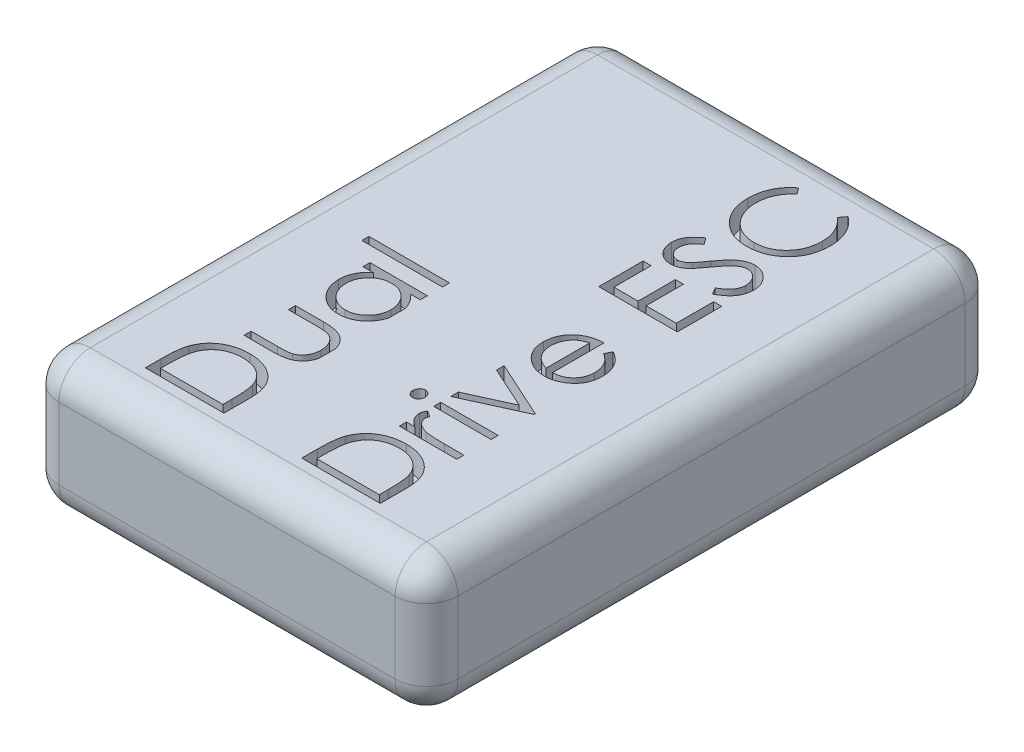
from build123d import *

# Parameters (mm, degrees)
SKETCH1_W           = 17.78
SKETCH1_H           = 25.4
BOSS_EXTRUDE1_DEPTH = 6
FILLET1_R           = 1.4
SKETCH2_W           = 3.58974359
SKETCH2_H           = 0.314102564
SKETCH2_W_2         = 2.557692308
CUT_EXTRUDE1_DEPTH  = 1


with BuildPart() as part:
    # Sketch1 → Boss-Extrude1 (new body)
    with BuildSketch(Plane(origin=(0, 0, 0), x_dir=(1, 0, 0), z_dir=(0, 1, 0))):
        with Locations((8.89, 12.7)):
            Rectangle(SKETCH1_W, SKETCH1_H)
    extrude(amount=BOSS_EXTRUDE1_DEPTH)

    # Fillet1
    fillet1_edges = [part.edges().sort_by_distance(p)[0] for p in [
        (17.78, 6, -12.7),
        (8.89, 6, -25.4),
        (0, 6, -12.7),
        (8.89, 0, -25.4),
        (17.78, 0, -12.7),
        (8.89, 0, 0),
        (0, 0, -12.7),
        (8.89, 6, 0),
        (0, 3, -25.4),
        (17.78, 3, -25.4),
        (17.78, 3, 0),
        (0, 3, 0),
    ]]
    fillet(fillet1_edges, radius=FILLET1_R)

    # Sketch2 → Cut-Extrude1 (cut)
    with BuildSketch(Plane(origin=(0, 6, 0), x_dir=(1, 0, 0), z_dir=(0, 1, 0))):
        with BuildLine():
            Line((3.403892312, 1.848717949), (6.903892312, 1.848717949))
            Line((6.903892312, 1.848717949), (6.903892312, 2.933353365))
            add(Edge.make_bspline(
                [(5.198062985, 4.720512821), (5.283343469, 4.720861509), (5.409315563, 4.713342182), (5.574129011, 4.691314552), (5.691735356, 4.666300928), (5.806063153, 4.635890145), (5.915896434, 4.596929309), (6.022236578, 4.552288757), (6.123667497, 4.500255599), (6.219702042, 4.443053958), (6.310299612, 4.382050173), (6.393449814, 4.315860667), (6.47133156, 4.246444464), (6.541864328, 4.172127597), (6.606333838, 4.093814865), (6.663660719, 4.011201923), (6.714745845, 3.923777373), (6.760429757, 3.830373639), (6.79853603, 3.728052702), (6.831538271, 3.617299225), (6.85779831, 3.497481653), (6.878949527, 3.369027162), (6.89845033, 3.180171866), (6.904427076, 3.033739775), (6.903892312, 2.933353365)],
                knots=[0, 0, 0, 0, 0.090812897, 0.134304288, 0.177036272, 0.218837427, 0.260261591, 0.301100084, 0.341636832, 0.381609041, 0.420147801, 0.457909661, 0.494760701, 0.531219285, 0.56696076, 0.602742115, 0.638232018, 0.674761113, 0.713377828, 0.754425315, 0.797801785, 0.843978981, 0.89306439, 1, 1, 1, 1], degree=3))
            add(Edge.make_bspline(
                [(3.530094235, 3.666025641), (3.558662483, 3.746791966), (3.611064859, 3.863508027), (3.698703507, 4.008186392), (3.772584338, 4.108669197), (3.854444017, 4.202214919), (3.943635575, 4.289907461), (4.042157086, 4.369578842), (4.148250416, 4.44247163), (4.260557449, 4.508211372), (4.37889391, 4.565350034), (4.502650765, 4.612801862), (4.631485957, 4.652204475), (4.765682526, 4.683214339), (4.954662157, 4.712058017), (5.09987701, 4.721034475), (5.198062985, 4.720512821)],
                knots=[0, 0, 0, 0, 0.121697081, 0.181159, 0.240076822, 0.298685898, 0.357632728, 0.417591519, 0.47848211, 0.540396536, 0.602335896, 0.664996664, 0.728553099, 0.793645821, 0.860531077, 1, 1, 1, 1], degree=3))
            add(Edge.make_bspline(
                [(3.403892312, 2.555448718), (3.404379803, 2.674191685), (3.406873159, 2.845918832), (3.420209511, 3.06607085), (3.434160152, 3.211507848), (3.451357158, 3.343974922), (3.478472088, 3.495280432), (3.507078253, 3.601012467), (3.530094235, 3.666025641)],
                knots=[0, 0, 0, 0, 0.317405911, 0.458843612, 0.589366542, 0.707831319, 0.815770031, 1, 1, 1, 1], degree=3))
            Line((3.403892312, 2.555448718), (3.403892312, 1.848717949))
        make_face()
        with BuildLine():
            Line((6.544917953, 2.564563301), (6.544917953, 2.162820513))
            Line((6.544917953, 2.162820513), (3.762866671, 2.162820513))
            Line((3.762866671, 2.162820513), (3.762866671, 2.408914263))
            add(Edge.make_bspline(
                [(3.861023722, 3.484435096), (3.842266774, 3.422417391), (3.821029132, 3.321003347), (3.800257251, 3.176211079), (3.786148017, 3.048324028), (3.776087002, 2.907281711), (3.765486713, 2.692769314), (3.762479496, 2.52509325), (3.762866671, 2.408914263)],
                knots=[0, 0, 0, 0, 0.179284514, 0.286582528, 0.405111483, 0.535592873, 0.67819021, 1, 1, 1, 1], degree=3))
            add(Edge.make_bspline(
                [(5.197361863, 4.406410256), (5.116923223, 4.407335302), (4.998426917, 4.398971193), (4.844543218, 4.37366388), (4.735564562, 4.346916578), (4.630876331, 4.312776218), (4.531056787, 4.270184057), (4.435051934, 4.22151678), (4.345077536, 4.163613625), (4.259984539, 4.10019796), (4.182029215, 4.029820183), (4.111036422, 3.953597809), (4.045891477, 3.872364203), (3.989249101, 3.783822405), (3.920685382, 3.657230417), (3.882808734, 3.554489103), (3.861023722, 3.484435096)],
                knots=[0, 0, 0, 0, 0.137812606, 0.203226247, 0.267174055, 0.330024003, 0.391794272, 0.453084399, 0.514333908, 0.574999993, 0.634865483, 0.694116315, 0.753441622, 0.8131258, 0.874079686, 1, 1, 1, 1], degree=3))
            add(Edge.make_bspline(
                [(6.455875485, 3.565064103), (6.43441375, 3.628346362), (6.39861513, 3.721547094), (6.333777936, 3.835782028), (6.280390418, 3.915894323), (6.219741892, 3.990222615), (6.153166261, 4.05963787), (6.080352823, 4.124053837), (6.001421409, 4.182478719), (5.917227461, 4.235398061), (5.827622195, 4.280827613), (5.73386533, 4.320388844), (5.635197712, 4.351721514), (5.532343082, 4.376397706), (5.386416121, 4.400007158), (5.273726642, 4.406389861), (5.197361863, 4.406410256)],
                knots=[0, 0, 0, 0, 0.123333124, 0.183116954, 0.241772982, 0.300566435, 0.359665179, 0.418864294, 0.479510805, 0.540462459, 0.601912774, 0.66446721, 0.727807097, 0.79247456, 0.859249308, 1, 1, 1, 1], degree=3))
            add(Edge.make_bspline(
                [(6.544917953, 2.564563301), (6.544863638, 2.675588593), (6.54274577, 2.835314447), (6.533155178, 3.038861014), (6.523600029, 3.170986374), (6.51088656, 3.289262806), (6.493398546, 3.420202653), (6.47307019, 3.510496157), (6.455875485, 3.565064103)],
                knots=[0, 0, 0, 0, 0.330627932, 0.475548836, 0.60674619, 0.725023803, 0.829742387, 1, 1, 1, 1], degree=3))
        make_face(mode=Mode.SUBTRACT)
        with BuildLine():
            add(Edge.make_bspline(
                [(6.903892312, 6.071303494), (6.899585564, 6.054697815), (6.887890906, 6.013127476), (6.865012698, 5.948266819), (6.834188811, 5.878250833), (6.799123772, 5.812106544), (6.75962864, 5.75005339), (6.716159851, 5.692230846), (6.669851527, 5.637608084), (6.61912434, 5.587701362), (6.564358079, 5.542144634), (6.505798845, 5.500740397), (6.444108482, 5.462780477), (6.378044292, 5.428428568), (6.30547258, 5.398916576), (6.225175389, 5.372861328), (6.136272919, 5.351551001), (6.038840899, 5.334207138), (5.933346209, 5.320261574), (5.775609156, 5.306845534), (5.652883591, 5.304345625), (5.568255293, 5.303846154)],
                knots=[0.185208779, 0.185208779, 0.185208779, 0.185208779, 0.210119037, 0.247908045, 0.284992266, 0.321132393, 0.356538176, 0.391703962, 0.426128007, 0.460451495, 0.494915681, 0.529481681, 0.564527673, 0.600052036, 0.637494925, 0.678177888, 0.722552113, 0.77015693, 0.821859616, 0.87705344, 1, 1, 1, 1], degree=3))
            Line((6.903892312, 6.071303494), (6.903892312, 6.828770188))
            add(Edge.make_bspline(
                [(5.591392312, 7.592307692), (5.673457092, 7.591867452), (5.792898559, 7.589165526), (5.946450043, 7.575969492), (6.049585734, 7.561864939), (6.14449966, 7.54474344), (6.23122363, 7.523098182), (6.309870492, 7.497106384), (6.38161416, 7.467805326), (6.446656266, 7.433178193), (6.508408978, 7.396367624), (6.565239654, 7.353782803), (6.620222386, 7.309338364), (6.669513906, 7.258736781), (6.71702055, 7.20587081), (6.759700957, 7.147833799), (6.798970399, 7.086310348), (6.834185097, 7.020720979), (6.865171889, 6.951225271), (6.887789183, 6.886641199), (6.899573547, 6.845233944), (6.903892312, 6.828770188)],
                knots=[0, 0, 0, 0, 0.120709054, 0.175567489, 0.226555659, 0.27374294, 0.317339005, 0.357878624, 0.395473238, 0.431137792, 0.466150532, 0.501072063, 0.535484186, 0.569994, 0.604815602, 0.639941181, 0.675790732, 0.712080754, 0.749315451, 0.787578099, 0.812604333, 0.812604333, 0.812604333, 0.812604333], degree=3))
            Line((5.591392312, 7.592307692), (4.346200004, 7.592307692))
            Line((4.346200004, 7.592307692), (4.346200004, 7.278205128))
            Line((4.346200004, 7.278205128), (5.532498081, 7.278205128))
            add(Edge.make_bspline(
                [(6.155795357, 7.226322115), (6.125162714, 7.23646969), (6.073027427, 7.247780585), (5.996101305, 7.258698792), (5.923152858, 7.266399606), (5.839888347, 7.271841165), (5.708508654, 7.276060025), (5.604979488, 7.279017732), (5.532498081, 7.278205128)],
                knots=[0, 0, 0, 0, 0.154073662, 0.254591451, 0.371465414, 0.504754566, 0.653494295, 1, 1, 1, 1], degree=3))
            add(Edge.make_bspline(
                [(6.634661543, 6.452984776), (6.634209163, 6.543394542), (6.620923713, 6.676524833), (6.563852359, 6.840195669), (6.506099292, 6.947066393), (6.435313027, 7.040947953), (6.325133217, 7.145437123), (6.226372601, 7.201906427), (6.155795357, 7.226322115)],
                knots=[0, 0, 0, 0, 0.279836964, 0.408371312, 0.53304287, 0.653596301, 0.770015738, 1, 1, 1, 1], degree=3))
            add(Edge.make_bspline(
                [(6.130554972, 5.667728365), (6.168190147, 5.68082342), (6.224252264, 5.701770619), (6.291992626, 5.742178526), (6.340296417, 5.77503258), (6.385098407, 5.812933545), (6.426322926, 5.855392618), (6.465525886, 5.900990874), (6.511916569, 5.968746352), (6.561585594, 6.061401759), (6.620378853, 6.227393544), (6.634463669, 6.362052652), (6.634661543, 6.452984776)],
                knots=[0, 0, 0, 0, 0.119715933, 0.178086164, 0.235971321, 0.294609768, 0.353536018, 0.413161309, 0.474545309, 0.599233517, 0.727029212, 1, 1, 1, 1], degree=3))
            add(Edge.make_bspline(
                [(5.532498081, 5.617948718), (5.599098764, 5.618274926), (5.695005316, 5.618482166), (5.817206542, 5.624534992), (5.896237763, 5.629938983), (5.96685675, 5.636934426), (6.044431201, 5.647167047), (6.098252257, 5.657711822), (6.130554972, 5.667728365)],
                knots=[0, 0, 0, 0, 0.332120377, 0.477936277, 0.60993181, 0.727031521, 0.831671423, 1, 1, 1, 1], degree=3))
            Line((5.532498081, 5.617948718), (4.346200004, 5.617948718))
            Line((4.346200004, 5.617948718), (4.346200004, 5.303846154))
            Line((4.346200004, 5.303846154), (5.568255293, 5.303846154))
        make_face()
        with BuildLine():
            add(Edge.make_bspline(
                [(6.903892312, 9.198215812), (6.900783799, 9.186373664), (6.886127831, 9.133524082), (6.854334552, 9.041409597), (6.798742165, 8.925737223), (6.732204067, 8.814677184), (6.652962371, 8.708804492), (6.562374582, 8.609732893), (6.463979534, 8.518501131), (6.359033991, 8.438438997), (6.247991729, 8.371689049), (6.132258403, 8.315857368), (6.010944133, 8.272904323), (5.840236952, 8.232227747), (5.707541296, 8.220720813), (5.61803494, 8.220512821)],
                knots=[0.171490765, 0.171490765, 0.171490765, 0.171490765, 0.189004127, 0.249930071, 0.310668454, 0.372328961, 0.43493911, 0.499575544, 0.564191208, 0.626735217, 0.688109334, 0.749293607, 0.810330528, 0.87190117, 1, 1, 1, 1], degree=3))
            Line((6.903892312, 9.198215812), (6.903892312, 9.91916593))
            add(Edge.make_bspline(
                [(6.461484459, 10.598717949), (6.540393159, 10.53084288), (6.65261668, 10.423659837), (6.765971114, 10.256087974), (6.834340493, 10.12771155), (6.877338423, 10.014051067), (6.897559203, 9.943712652), (6.903892312, 9.91916593)],
                knots=[0, 0, 0, 0, 0.262459729, 0.386304973, 0.507192751, 0.627321527, 0.691022216, 0.691022216, 0.691022216, 0.691022216], degree=3))
            Line((6.461484459, 10.598717949), (6.903892312, 10.598717949))
            Line((6.903892312, 10.598717949), (6.903892312, 10.912820513))
            Line((6.903892312, 10.912820513), (4.346200004, 10.912820513))
            Line((4.346200004, 10.912820513), (4.346200004, 10.598717949))
            Line((4.346200004, 10.598717949), (4.819457216, 10.598717949))
            add(Edge.make_bspline(
                [(4.301328209, 9.563862179), (4.301650916, 9.666040288), (4.314702251, 9.817825821), (4.368789831, 10.009756886), (4.42239592, 10.14471049), (4.495221779, 10.271123156), (4.616775523, 10.434181471), (4.735556764, 10.535767268), (4.819457216, 10.598717949)],
                knots=[0, 0, 0, 0, 0.254680701, 0.376054673, 0.495308093, 0.61515024, 0.738120896, 1, 1, 1, 1], degree=3))
            add(Edge.make_bspline(
                [(5.61803494, 8.220512821), (5.530217176, 8.221030474), (5.399602626, 8.231761949), (5.231870609, 8.27375778), (5.112515344, 8.317266747), (4.998174846, 8.373119093), (4.88877094, 8.441044352), (4.784001522, 8.521064263), (4.686330253, 8.613316454), (4.596109829, 8.713251274), (4.517700088, 8.82016002), (4.449985758, 8.931383195), (4.396322984, 9.048646612), (4.352948719, 9.170212192), (4.312269235, 9.341424826), (4.302125831, 9.474448947), (4.301328209, 9.563862179)],
                knots=[0, 0, 0, 0, 0.12607881, 0.186904093, 0.247573935, 0.308003356, 0.369131898, 0.432033228, 0.496790794, 0.561610823, 0.624913866, 0.686726349, 0.748078833, 0.809582291, 0.871630743, 1, 1, 1, 1], degree=3))
        make_face()
        with BuildLine():
            add(Edge.make_bspline(
                [(4.615430774, 9.56806891), (4.615846942, 9.477582693), (4.630801914, 9.342163886), (4.687452486, 9.17120967), (4.74444506, 9.04994916), (4.817558238, 8.938063565), (4.90367675, 8.83631266), (5.004279261, 8.747842662), (5.115757957, 8.671729268), (5.235932658, 8.610735554), (5.402992807, 8.552800267), (5.534073649, 8.533476622), (5.621540549, 8.534615385)],
                knots=[0, 0, 0, 0, 0.169607377, 0.25249627, 0.336272119, 0.419776679, 0.502030168, 0.585102511, 0.669819334, 0.754164659, 0.83664481, 1, 1, 1, 1], degree=3))
            add(Edge.make_bspline(
                [(5.630655133, 10.598717949), (5.56112758, 10.598521133), (5.458071799, 10.589670304), (5.325899592, 10.558458154), (5.232457451, 10.526144537), (5.143822291, 10.483644597), (5.059358565, 10.432399168), (4.97950536, 10.371493079), (4.905362228, 10.301910562), (4.837736001, 10.225745306), (4.777370902, 10.145150798), (4.72778527, 10.059171975), (4.686732374, 9.969255207), (4.654117332, 9.875242857), (4.624441028, 9.741614871), (4.614412106, 9.638167469), (4.615430774, 9.56806891)],
                knots=[0, 0, 0, 0, 0.129188088, 0.191218683, 0.251912818, 0.312507474, 0.373494434, 0.4351516, 0.498741474, 0.562095217, 0.624186567, 0.685475718, 0.746096815, 0.807611636, 0.869966581, 1, 1, 1, 1], degree=3))
            add(Edge.make_bspline(
                [(6.634661543, 9.565264423), (6.633987574, 9.655484224), (6.619209467, 9.791457089), (6.561697464, 9.963895221), (6.504115734, 10.087828827), (6.432309998, 10.203174213), (6.348266432, 10.306347606), (6.251191378, 10.39461617), (6.143265213, 10.468122752), (6.025705509, 10.52635534), (5.85663785, 10.584229024), (5.721294711, 10.598133781), (5.630655133, 10.598717949)],
                knots=[0, 0, 0, 0, 0.168704239, 0.252747802, 0.338456244, 0.423339694, 0.50581298, 0.586129024, 0.667468815, 0.748851908, 0.830411486, 1, 1, 1, 1], degree=3))
            add(Edge.make_bspline(
                [(5.621540549, 8.534615385), (5.708408154, 8.535476362), (5.839836216, 8.551740456), (6.00623832, 8.612068373), (6.127373361, 8.673004137), (6.239942696, 8.750006478), (6.342352084, 8.838393997), (6.429816564, 8.940634263), (6.503110704, 9.053519261), (6.562188391, 9.174139599), (6.617563988, 9.343604225), (6.635080528, 9.476362792), (6.634661543, 9.565264423)],
                knots=[0, 0, 0, 0, 0.162872505, 0.245091789, 0.33042237, 0.416115765, 0.49985141, 0.583013312, 0.667130037, 0.751291147, 0.833770899, 1, 1, 1, 1], degree=3))
        make_face(mode=Mode.SUBTRACT)
        with Locations((5.109020517, 11.742948718)):
            Rectangle(SKETCH2_W, SKETCH2_H)
        with BuildLine():
            add(Edge.make_bspline(
                [(12.166011703, 4.720512821), (12.251292187, 4.720861509), (12.377264281, 4.713342182), (12.542077729, 4.691314552), (12.659684074, 4.666300928), (12.774011871, 4.635890145), (12.883845152, 4.596929309), (12.990185296, 4.552288757), (13.091616215, 4.500255599), (13.18765076, 4.443053958), (13.27824833, 4.382050173), (13.361398532, 4.315860667), (13.439280278, 4.246444464), (13.509813046, 4.172127597), (13.574282555, 4.093814865), (13.631609437, 4.011201923), (13.682694563, 3.923777373), (13.728378475, 3.830373639), (13.766484748, 3.728052702), (13.799486989, 3.617299225), (13.825747028, 3.497481653), (13.846898245, 3.369027162), (13.866399048, 3.180171866), (13.872375794, 3.033739775), (13.87184103, 2.933353365)],
                knots=[0, 0, 0, 0, 0.090812897, 0.134304288, 0.177036272, 0.218837427, 0.260261591, 0.301100084, 0.341636832, 0.381609041, 0.420147801, 0.457909661, 0.494760701, 0.531219285, 0.56696076, 0.602742115, 0.638232018, 0.674761113, 0.713377828, 0.754425315, 0.797801785, 0.843978981, 0.89306439, 1, 1, 1, 1], degree=3))
            Line((13.87184103, 2.933353365), (13.87184103, 1.848717949))
            Line((13.87184103, 1.848717949), (10.37184103, 1.848717949))
            Line((10.37184103, 1.848717949), (10.37184103, 2.555448718))
            add(Edge.make_bspline(
                [(10.37184103, 2.555448718), (10.372328521, 2.674191685), (10.374821877, 2.845918832), (10.388158229, 3.06607085), (10.40210887, 3.211507848), (10.419305876, 3.343974922), (10.446420806, 3.495280432), (10.475026971, 3.601012467), (10.498042953, 3.666025641)],
                knots=[0, 0, 0, 0, 0.317405911, 0.458843612, 0.589366542, 0.707831319, 0.815770031, 1, 1, 1, 1], degree=3))
            add(Edge.make_bspline(
                [(10.498042953, 3.666025641), (10.526611201, 3.746791966), (10.579013577, 3.863508027), (10.666652225, 4.008186392), (10.740533056, 4.108669197), (10.822392735, 4.202214919), (10.911584293, 4.289907461), (11.010105804, 4.369578842), (11.116199134, 4.44247163), (11.228506167, 4.508211372), (11.346842628, 4.565350034), (11.470599482, 4.612801862), (11.599434675, 4.652204475), (11.733631244, 4.683214339), (11.922610875, 4.712058017), (12.067825728, 4.721034475), (12.166011703, 4.720512821)],
                knots=[0, 0, 0, 0, 0.121697081, 0.181159, 0.240076822, 0.298685898, 0.357632728, 0.417591519, 0.47848211, 0.540396536, 0.602335896, 0.664996664, 0.728553099, 0.793645821, 0.860531077, 1, 1, 1, 1], degree=3))
        make_face()
        with BuildLine():
            add(Edge.make_bspline(
                [(10.82897244, 3.484435096), (10.810215492, 3.422417391), (10.78897785, 3.321003347), (10.768205969, 3.176211079), (10.754096735, 3.048324028), (10.74403572, 2.907281711), (10.733435431, 2.692769314), (10.730428213, 2.52509325), (10.730815389, 2.408914263)],
                knots=[0, 0, 0, 0, 0.179284514, 0.286582528, 0.405111483, 0.535592873, 0.67819021, 1, 1, 1, 1], degree=3))
            Line((10.730815389, 2.408914263), (10.730815389, 2.162820513))
            Line((10.730815389, 2.162820513), (13.512866671, 2.162820513))
            Line((13.512866671, 2.162820513), (13.512866671, 2.564563301))
            add(Edge.make_bspline(
                [(13.512866671, 2.564563301), (13.512812356, 2.675588593), (13.510694488, 2.835314447), (13.501103896, 3.038861014), (13.491548747, 3.170986374), (13.478835278, 3.289262806), (13.461347263, 3.420202653), (13.441018908, 3.510496157), (13.423824203, 3.565064103)],
                knots=[0, 0, 0, 0, 0.330627932, 0.475548836, 0.60674619, 0.725023803, 0.829742387, 1, 1, 1, 1], degree=3))
            add(Edge.make_bspline(
                [(13.423824203, 3.565064103), (13.402362468, 3.628346362), (13.366563848, 3.721547094), (13.301726654, 3.835782028), (13.248339136, 3.915894323), (13.18769061, 3.990222615), (13.121114979, 4.05963787), (13.048301541, 4.124053837), (12.969370127, 4.182478719), (12.885176179, 4.235398061), (12.795570913, 4.280827613), (12.701814048, 4.320388844), (12.60314643, 4.351721514), (12.5002918, 4.376397706), (12.354364838, 4.400007158), (12.241675359, 4.406389861), (12.165310581, 4.406410256)],
                knots=[0, 0, 0, 0, 0.123333124, 0.183116954, 0.241772982, 0.300566435, 0.359665179, 0.418864294, 0.479510805, 0.540462459, 0.601912774, 0.66446721, 0.727807097, 0.79247456, 0.859249308, 1, 1, 1, 1], degree=3))
            add(Edge.make_bspline(
                [(12.165310581, 4.406410256), (12.084871941, 4.407335302), (11.966375635, 4.398971193), (11.812491936, 4.37366388), (11.70351328, 4.346916578), (11.598825049, 4.312776218), (11.499005505, 4.270184057), (11.403000652, 4.22151678), (11.313026254, 4.163613625), (11.227933257, 4.10019796), (11.149977933, 4.029820183), (11.07898514, 3.953597809), (11.013840195, 3.872364203), (10.957197819, 3.783822405), (10.8886341, 3.657230417), (10.850757452, 3.554489103), (10.82897244, 3.484435096)],
                knots=[0, 0, 0, 0, 0.137812606, 0.203226247, 0.267174055, 0.330024003, 0.391794272, 0.453084399, 0.514333908, 0.574999993, 0.634865483, 0.694116315, 0.753441622, 0.8131258, 0.874079686, 1, 1, 1, 1], degree=3))
        make_face(mode=Mode.SUBTRACT)
        with BuildLine():
            add(Edge.make_bspline(
                [(12.134461222, 5.629166667), (12.179331611, 5.617273784), (12.25454629, 5.606117617), (12.364256182, 5.593662285), (12.466969135, 5.586598681), (12.583815287, 5.580003393), (12.767073867, 5.574799222), (12.911517635, 5.572496859), (13.012265709, 5.573076923)],
                knots=[0, 0, 0, 0, 0.157725797, 0.258597615, 0.37588863, 0.508164411, 0.657031921, 1, 1, 1, 1], degree=3))
            Line((13.012265709, 5.573076923), (13.87184103, 5.573076923))
            Line((13.87184103, 5.573076923), (13.87184103, 5.258974359))
            Line((13.87184103, 5.258974359), (11.314148722, 5.258974359))
            Line((11.314148722, 5.258974359), (11.314148722, 5.573076923))
            Line((11.314148722, 5.573076923), (11.690651126, 5.573076923))
            add(Edge.make_bspline(
                [(11.690651126, 5.573076923), (11.62270084, 5.615873408), (11.529448888, 5.684534953), (11.425742175, 5.789598597), (11.367343807, 5.867534388), (11.323289923, 5.947693555), (11.282028905, 6.055725891), (11.269405481, 6.140893539), (11.269276927, 6.197075321)],
                knots=[0, 0, 0, 0, 0.306020525, 0.438853895, 0.560992174, 0.675733502, 0.786177817, 1, 1, 1, 1], degree=3))
            add(Edge.make_bspline(
                [(11.269276927, 6.197075321), (11.269626348, 6.242051773), (11.28651935, 6.338518604), (11.330057261, 6.426171715), (11.356917152, 6.470512821)],
                knots=[0, 0, 0, 0, 0.463523195, 1, 1, 1, 1], degree=3))
            Line((11.356917152, 6.470512821), (11.628952408, 6.298036859))
            add(Edge.make_bspline(
                [(11.628952408, 6.298036859), (11.616282074, 6.269423821), (11.593026436, 6.217951163), (11.58370188, 6.162164008), (11.583379492, 6.137479968)],
                knots=[0, 0, 0, 0, 0.560229945, 1, 1, 1, 1], degree=3))
            add(Edge.make_bspline(
                [(11.583379492, 6.137479968), (11.583117463, 6.085842212), (11.602581586, 6.007433631), (11.658178919, 5.911916672), (11.706532436, 5.853963249), (11.753080193, 5.808937195), (11.793805084, 5.776554697), (11.83989689, 5.747491867), (11.889568237, 5.719297048), (11.944071197, 5.693114133), (12.025438474, 5.660998548), (12.089917484, 5.640915309), (12.134461222, 5.629166667)],
                knots=[0, 0, 0, 0, 0.191277622, 0.294661612, 0.409746928, 0.471345357, 0.53581987, 0.603222207, 0.674198699, 0.748603288, 0.828337685, 1, 1, 1, 1], degree=3))
        make_face()
        with Locations((12.592994876, 6.941666667)):
            Rectangle(SKETCH2_W_2, SKETCH2_H)
        with BuildLine():
            add(Edge.make_bspline(
                [(10.507858658, 6.65), (10.472239205, 6.649840836), (10.41882676, 6.661084016), (10.356043455, 6.69721575), (10.315007142, 6.734647283), (10.280802133, 6.779292275), (10.246408238, 6.846360894), (10.236989057, 6.902861882), (10.237225645, 6.940264423)],
                knots=[0, 0, 0, 0, 0.242149081, 0.363437476, 0.489745393, 0.618114845, 0.744893781, 1, 1, 1, 1], degree=3))
            add(Edge.make_bspline(
                [(10.237225645, 6.940264423), (10.237299877, 6.978262658), (10.245997837, 7.035663598), (10.280788898, 7.103373581), (10.315233617, 7.147961747), (10.355793182, 7.186163749), (10.41890073, 7.222167527), (10.472201229, 7.233534488), (10.507858658, 7.233333333)],
                knots=[0, 0, 0, 0, 0.258284092, 0.384341125, 0.511979615, 0.638632008, 0.759229763, 1, 1, 1, 1], degree=3))
            add(Edge.make_bspline(
                [(10.507858658, 7.233333333), (10.542798866, 7.233407628), (10.595262075, 7.222095036), (10.657213795, 7.185935601), (10.69769419, 7.147986294), (10.732119981, 7.103367106), (10.766917686, 7.035668013), (10.775611545, 6.978260351), (10.775687184, 6.940264423)],
                knots=[0, 0, 0, 0, 0.23754632, 0.357497051, 0.484917122, 0.613329268, 0.74015037, 1, 1, 1, 1], degree=3))
            add(Edge.make_bspline(
                [(10.775687184, 6.940264423), (10.77592237, 6.902864172), (10.766507275, 6.846356513), (10.732106693, 6.77929881), (10.697920802, 6.734622611), (10.65696552, 6.697441392), (10.595334253, 6.661158417), (10.542762322, 6.649966148), (10.507858658, 6.65)],
                knots=[0, 0, 0, 0, 0.256661403, 0.384213213, 0.513365233, 0.640443152, 0.761085005, 1, 1, 1, 1], degree=3))
        make_face()
        Polygon((13.87184103, 8.714102564), (11.314148722, 7.547435897), (11.314148722, 7.887479968), (13.176328209, 8.736538462), (11.314148722, 9.585596955), (11.314148722, 9.925641026), (13.87184103, 8.758974359), align=None)
        with BuildLine():
            add(Edge.make_bspline(
                [(13.602610261, 11.666526442), (13.602984348, 11.72874081), (13.595443395, 11.821976176), (13.570271713, 11.943989804), (13.543359067, 12.033024467), (13.511797254, 12.118515064), (13.474661757, 12.198121726), (13.43231941, 12.270790605), (13.384205752, 12.338977956), (13.325147856, 12.404742977), (13.22122766, 12.499250884), (13.130313995, 12.564872369), (13.064148722, 12.608133013)],
                knots=[0, 0, 0, 0, 0.163889066, 0.245673987, 0.327919217, 0.408808503, 0.485688835, 0.559113362, 0.630217195, 0.705259405, 0.791569938, 1, 1, 1, 1], degree=3))
            Line((13.064148722, 12.608133013), (13.210683177, 12.887179487))
            add(Edge.make_bspline(
                [(13.210683177, 12.887179487), (13.288235348, 12.845503305), (13.397479212, 12.776627451), (13.526509976, 12.669057028), (13.608136179, 12.58397902), (13.680205487, 12.494752281), (13.742374094, 12.399726922), (13.795754882, 12.299667205), (13.839503957, 12.193473302), (13.87386607, 12.081274652), (13.908650346, 11.919125436), (13.916376902, 11.792019958), (13.916712825, 11.705789263)],
                knots=[0, 0, 0, 0, 0.181688874, 0.265545891, 0.3460389, 0.42459718, 0.501912463, 0.580013453, 0.65829144, 0.738532659, 0.821866591, 1, 1, 1, 1], degree=3))
            add(Edge.make_bspline(
                [(13.916712825, 11.705789263), (13.916673941, 11.610018584), (13.90567766, 11.469096885), (13.862531302, 11.289865048), (13.818605634, 11.166654981), (13.761167986, 11.051912355), (13.691211317, 10.945411415), (13.609078021, 10.846592611), (13.514062917, 10.758565551), (13.412376689, 10.679332275), (13.306436058, 10.609368109), (13.196608033, 10.5511505), (13.083545324, 10.503060755), (12.967507674, 10.465162114), (12.806905928, 10.428852137), (12.683015723, 10.420182903), (12.600006094, 10.419230769)],
                knots=[0, 0, 0, 0, 0.139627803, 0.204794612, 0.268132233, 0.329810388, 0.391297413, 0.453428897, 0.51654643, 0.579625368, 0.641112392, 0.701286905, 0.760489034, 0.819933556, 0.878920809, 1, 1, 1, 1], degree=3))
            add(Edge.make_bspline(
                [(12.600006094, 10.419230769), (12.522212392, 10.420184057), (12.406083532, 10.427460137), (12.255539821, 10.459087517), (12.146652129, 10.49123495), (12.041111879, 10.532814051), (11.903600843, 10.600986828), (11.807531572, 10.666150661), (11.746039748, 10.713701923)],
                knots=[0, 0, 0, 0, 0.2537679, 0.377428427, 0.500550841, 0.623295883, 0.746578332, 1, 1, 1, 1], degree=3))
            add(Edge.make_bspline(
                [(11.746039748, 10.713701923), (11.669808761, 10.773644172), (11.56556052, 10.87374076), (11.45352949, 11.027437931), (11.385756829, 11.149339126), (11.333724311, 11.279484211), (11.283120875, 11.466489568), (11.269431709, 11.613806893), (11.269276927, 11.713501603)],
                knots=[0, 0, 0, 0, 0.253207252, 0.374634022, 0.495345946, 0.616345853, 0.739634472, 1, 1, 1, 1], degree=3))
            add(Edge.make_bspline(
                [(11.269276927, 11.713501603), (11.26874337, 11.816374269), (11.283917371, 11.968151907), (11.336767839, 12.161037304), (11.393123421, 12.29429091), (11.463121362, 12.420574305), (11.582565329, 12.578522356), (11.691926295, 12.682113367), (11.772682376, 12.743449519)],
                knots=[0, 0, 0, 0, 0.259049325, 0.381904125, 0.502516251, 0.622728183, 0.744726388, 1, 1, 1, 1], degree=3))
            add(Edge.make_bspline(
                [(11.772682376, 12.743449519), (11.831571199, 12.789336171), (11.927210363, 12.849245211), (12.063996385, 12.912855979), (12.172878119, 12.951232757), (12.286704469, 12.98224289), (12.449060588, 13.012844374), (12.575042927, 13.020205407), (12.660302568, 13.021794872)],
                knots=[0, 0, 0, 0, 0.236254763, 0.356174434, 0.477249655, 0.601539871, 0.729618382, 1, 1, 1, 1], degree=3))
            Line((12.660302568, 13.021794872), (12.660302568, 10.733333333))
            add(Edge.make_bspline(
                [(12.660302568, 10.733333333), (12.726548579, 10.735122058), (12.824404838, 10.744002404), (12.949618129, 10.774282935), (13.036700709, 10.8055287), (13.119630956, 10.843401614), (13.197792964, 10.889785711), (13.270830889, 10.945125704), (13.339398076, 11.006851283), (13.400458648, 11.075558413), (13.455111112, 11.147841142), (13.500914187, 11.224734744), (13.538103449, 11.305632697), (13.56717452, 11.390404972), (13.59424098, 11.510387037), (13.602959945, 11.603515288), (13.602610261, 11.666526442)],
                knots=[0, 0, 0, 0, 0.134475588, 0.198391058, 0.260753477, 0.321829223, 0.383037238, 0.444653123, 0.507398011, 0.569825238, 0.630777641, 0.690928687, 0.750945133, 0.811049477, 0.872330853, 1, 1, 1, 1], degree=3))
        make_face()
        with BuildLine():
            add(Edge.make_bspline(
                [(11.823163145, 11.070572917), (11.852521996, 11.035653232), (11.903476995, 10.988566906), (11.978286657, 10.931507237), (12.041704413, 10.892817877), (12.109959302, 10.85609848), (12.210536354, 10.810227363), (12.290835162, 10.782660748), (12.346200004, 10.766286058)],
                knots=[0, 0, 0, 0, 0.222589307, 0.338513269, 0.459695873, 0.585518942, 0.717506562, 1, 1, 1, 1], degree=3))
            Line((12.346200004, 10.766286058), (12.346200004, 12.707692308))
            add(Edge.make_bspline(
                [(12.346200004, 12.707692308), (12.265453859, 12.688330749), (12.15207292, 12.647611907), (12.014726252, 12.575969112), (11.929104795, 12.514077837), (11.852953332, 12.444580226), (11.787465293, 12.363212414), (11.727110348, 12.273486164), (11.67683664, 12.173618488), (11.635570374, 12.067549026), (11.59478074, 11.920373886), (11.584171694, 11.805785396), (11.583379492, 11.729627404)],
                knots=[0, 0, 0, 0, 0.18478247, 0.26752515, 0.344438618, 0.419646412, 0.496623373, 0.576671797, 0.660316531, 0.745260457, 0.830065278, 1, 1, 1, 1], degree=3))
            add(Edge.make_bspline(
                [(11.583379492, 11.729627404), (11.583120698, 11.66766623), (11.590129955, 11.575737296), (11.615372083, 11.457158349), (11.642684247, 11.372933112), (11.675976348, 11.29181934), (11.730819921, 11.187065098), (11.784774219, 11.116051079), (11.823163145, 11.070572917)],
                knots=[0, 0, 0, 0, 0.25916286, 0.38419376, 0.506327947, 0.629067198, 0.750648357, 1, 1, 1, 1], degree=3))
        make_face(mode=Mode.SUBTRACT)
        Polygon((13.87184103, 15.085897436), (10.37184103, 15.085897436), (10.37184103, 17.06025641), (10.730815389, 17.06025641), (10.730815389, 15.4), (11.807738466, 15.4), (11.807738466, 17.06025641), (12.166712825, 17.06025641), (12.166712825, 15.4), (13.512866671, 15.4), (13.512866671, 17.06025641), (13.87184103, 17.06025641), align=None)
        with BuildLine():
            add(Edge.make_bspline(
                [(13.96158462, 18.393790064), (13.961899228, 18.341207946), (13.955545414, 18.263194029), (13.938348013, 18.160968597), (13.918200654, 18.08735341), (13.893716539, 18.015316289), (13.863580293, 17.945168789), (13.827461923, 17.876878514), (13.786169531, 17.810058004), (13.738102059, 17.744895203), (13.682167194, 17.681930397), (13.619790719, 17.619508133), (13.550010965, 17.558067324), (13.472052824, 17.498964097), (13.355683553, 17.419166884), (13.261805711, 17.36472905), (13.196660742, 17.329487179)],
                knots=[0, 0, 0, 0, 0.113693769, 0.169174509, 0.224154701, 0.278714264, 0.333787494, 0.389233619, 0.445813093, 0.503694135, 0.564282525, 0.627962766, 0.694643383, 0.765377452, 0.839614674, 1, 1, 1, 1], degree=3))
            Line((13.196660742, 17.329487179), (13.019276927, 17.625360577))
            add(Edge.make_bspline(
                [(13.019276927, 17.625360577), (13.108221447, 17.676595871), (13.23295418, 17.757510005), (13.374204582, 17.884705462), (13.457117681, 17.97967175), (13.522276668, 18.077943778), (13.58371784, 18.212938486), (13.602799738, 18.321791838), (13.602610261, 18.393790064)],
                knots=[0, 0, 0, 0, 0.3046461, 0.438546905, 0.562322299, 0.677432543, 0.786897393, 1, 1, 1, 1], degree=3))
            add(Edge.make_bspline(
                [(13.602610261, 18.393790064), (13.602855269, 18.454566407), (13.593053052, 18.545605406), (13.557805731, 18.661713858), (13.522374025, 18.744530192), (13.478759511, 18.821271687), (13.42734505, 18.88964622), (13.367934045, 18.947378264), (13.30272996, 18.995249855), (13.232813896, 19.032253206), (13.136872923, 19.0696798), (13.059906171, 19.078594803), (13.009461222, 19.079487179)],
                knots=[0, 0, 0, 0, 0.180992327, 0.270378773, 0.360477559, 0.448694185, 0.532623346, 0.614315552, 0.694490847, 0.772638072, 0.84928353, 1, 1, 1, 1], degree=3))
            add(Edge.make_bspline(
                [(13.009461222, 19.079487179), (12.950291952, 19.080098875), (12.826923236, 19.055262111), (12.718107147, 18.992602371), (12.665911543, 18.953986378)],
                knots=[0, 0, 0, 0, 0.475390581, 1, 1, 1, 1], degree=3))
            add(Edge.make_bspline(
                [(12.665911543, 18.953986378), (12.623323652, 18.92176218), (12.558923818, 18.867077212), (12.476478389, 18.782735496), (12.408236497, 18.70810673), (12.337059372, 18.624752383), (12.233782944, 18.497459799), (12.159087764, 18.394323926), (12.107818594, 18.322976763)],
                knots=[0, 0, 0, 0, 0.189534325, 0.299204829, 0.41837415, 0.548365785, 0.688129118, 1, 1, 1, 1], degree=3))
            add(Edge.make_bspline(
                [(12.107818594, 18.322976763), (12.058254699, 18.252152645), (11.984709, 18.153027079), (11.888966821, 18.02925144), (11.826676252, 17.952000008), (11.770085673, 17.885621805), (11.708335287, 17.816628281), (11.661601788, 17.773613002), (11.631756895, 17.749459135)],
                knots=[0, 0, 0, 0, 0.347081672, 0.495567816, 0.628357302, 0.74551967, 0.845830751, 1, 1, 1, 1], degree=3))
            add(Edge.make_bspline(
                [(11.631756895, 17.749459135), (11.591674531, 17.718550281), (11.530208378, 17.675293463), (11.442636166, 17.629468075), (11.376350134, 17.602166059), (11.308942774, 17.580129009), (11.216831079, 17.559529161), (11.146109093, 17.553614738), (11.098904331, 17.553846154)],
                knots=[0, 0, 0, 0, 0.262550464, 0.388251856, 0.511530984, 0.633734148, 0.755401792, 1, 1, 1, 1], degree=3))
            add(Edge.make_bspline(
                [(11.098904331, 17.553846154), (11.025664433, 17.553666017), (10.916716025, 17.567486234), (10.779385724, 17.614089063), (10.683070614, 17.662339589), (10.595049692, 17.724567897), (10.514530369, 17.796873125), (10.445919756, 17.882200925), (10.386893507, 17.976664396), (10.340267641, 18.079516284), (10.294614825, 18.224993252), (10.28278258, 18.339722057), (10.28209744, 18.416225962)],
                knots=[0, 0, 0, 0, 0.165750923, 0.246236977, 0.327403713, 0.408725528, 0.489629677, 0.571609868, 0.655742455, 0.741223679, 0.826577067, 1, 1, 1, 1], degree=3))
            add(Edge.make_bspline(
                [(10.28209744, 18.416225962), (10.281677018, 18.498243416), (10.297588868, 18.620879118), (10.350790945, 18.776454994), (10.397163317, 18.869729923), (10.443254067, 18.942886324), (10.485316618, 18.998621566), (10.53364396, 19.0554071), (10.589248598, 19.112636793), (10.651031698, 19.170858478), (10.745029011, 19.251919691), (10.820841493, 19.310623861), (10.874545357, 19.348717949)],
                knots=[0, 0, 0, 0, 0.213204388, 0.318561518, 0.426500592, 0.483340369, 0.543284906, 0.607974344, 0.677198563, 0.75074108, 0.82875151, 1, 1, 1, 1], degree=3))
            Line((10.874545357, 19.348717949), (11.089789748, 19.064763622))
            add(Edge.make_bspline(
                [(11.089789748, 19.064763622), (11.046844593, 19.032244509), (10.986715441, 18.982811369), (10.911136395, 18.917257565), (10.863939453, 18.870413728), (10.820500226, 18.827512243), (10.783967186, 18.785136475), (10.753190343, 18.744919052), (10.720279633, 18.694346515), (10.688681407, 18.630285126), (10.651212718, 18.523258444), (10.64148993, 18.437983511), (10.641071799, 18.381169872)],
                knots=[0, 0, 0, 0, 0.18959042, 0.27412816, 0.352111321, 0.423687273, 0.489026015, 0.548936192, 0.601892205, 0.701259033, 0.799632682, 1, 1, 1, 1], degree=3))
            add(Edge.make_bspline(
                [(10.641071799, 18.381169872), (10.639775615, 18.311470486), (10.655478136, 18.209717408), (10.70954555, 18.087065179), (10.765964863, 18.010397506), (10.833314211, 17.94718196), (10.936063876, 17.884845577), (11.025296781, 17.868093465), (11.084180774, 17.867948718)],
                knots=[0, 0, 0, 0, 0.275822022, 0.401868693, 0.527874505, 0.650458955, 0.765963766, 1, 1, 1, 1], degree=3))
            add(Edge.make_bspline(
                [(11.084180774, 17.867948718), (11.122042846, 17.866961019), (11.178082327, 17.874989823), (11.251418845, 17.894388161), (11.306158045, 17.916515399), (11.361638721, 17.947403272), (11.442322029, 18.00464342), (11.498450688, 18.059238615), (11.536404331, 18.098617788)],
                knots=[0, 0, 0, 0, 0.216059268, 0.322956381, 0.434131058, 0.553424066, 0.686081248, 1, 1, 1, 1], degree=3))
            add(Edge.make_bspline(
                [(11.536404331, 18.098617788), (11.552889195, 18.116605805), (11.579967821, 18.149500533), (11.61886985, 18.20170817), (11.659470809, 18.255158417), (11.706544785, 18.319131888), (11.781979523, 18.42514419), (11.842739377, 18.509180361), (11.884861863, 18.569070513)],
                knots=[0, 0, 0, 0, 0.124951974, 0.218093899, 0.333502411, 0.468789179, 0.624937586, 1, 1, 1, 1], degree=3))
            add(Edge.make_bspline(
                [(11.884861863, 18.569070513), (11.938216275, 18.642719125), (12.016443456, 18.749097795), (12.125093244, 18.880160059), (12.201465068, 18.965629057), (12.275003946, 19.042491384), (12.346533322, 19.109976415), (12.415585339, 19.168383637), (12.503511528, 19.232141349), (12.612503714, 19.296397543), (12.78714247, 19.369067296), (12.92427392, 19.393609672), (13.014369075, 19.393589744)],
                knots=[0, 0, 0, 0, 0.187763162, 0.272381231, 0.35130177, 0.424311551, 0.491881862, 0.554202887, 0.610843189, 0.715917624, 0.814550236, 1, 1, 1, 1], degree=3))
            add(Edge.make_bspline(
                [(13.014369075, 19.393589744), (13.076578391, 19.394550687), (13.168682852, 19.384423319), (13.287765639, 19.354685956), (13.372549816, 19.321905846), (13.454862767, 19.281174952), (13.533155918, 19.230251211), (13.608949759, 19.170910484), (13.680119624, 19.102875878), (13.745533667, 19.028468139), (13.803482823, 18.949541291), (13.852910995, 18.866919239), (13.89228629, 18.779706922), (13.92324988, 18.688842532), (13.953676145, 18.560740529), (13.961848648, 18.460948835), (13.96158462, 18.393790064)],
                knots=[0, 0, 0, 0, 0.121796172, 0.180951717, 0.240298819, 0.299757378, 0.360799729, 0.423165447, 0.488345809, 0.553642156, 0.617280622, 0.680181591, 0.742141564, 0.804628492, 0.868235573, 1, 1, 1, 1], degree=3))
        make_face()
        with BuildLine():
            add(Edge.make_bspline(
                [(10.28209744, 21.815264423), (10.281952819, 21.894841467), (10.287339108, 22.012970678), (10.30838821, 22.16746922), (10.329401383, 22.27910536), (10.35589593, 22.388066116), (10.388908104, 22.494146921), (10.428213588, 22.597088191), (10.47309806, 22.696856462), (10.523570587, 22.792778153), (10.57903544, 22.884793423), (10.639213235, 22.972534035), (10.704717009, 23.055549103), (10.775014641, 23.133921067), (10.874225255, 23.234116307), (10.957326705, 23.300126181), (11.014068594, 23.342307692)],
                knots=[0, 0, 0, 0, 0.135665818, 0.20118959, 0.265648698, 0.329225271, 0.392226355, 0.454892777, 0.516942032, 0.578597434, 0.639539568, 0.699983577, 0.759836562, 0.819651088, 0.87937002, 1, 1, 1, 1], degree=3))
            Line((11.014068594, 23.342307692), (11.224405133, 23.067467949))
            add(Edge.make_bspline(
                [(11.224405133, 23.067467949), (11.177439953, 23.029214015), (11.110219931, 22.968601504), (11.028399628, 22.880933936), (10.971083739, 22.813069774), (10.919828895, 22.741051328), (10.870624467, 22.667645165), (10.827547299, 22.590178091), (10.774912214, 22.483600174), (10.721259547, 22.343635565), (10.658467328, 22.106414797), (10.640555233, 21.920764352), (10.641071799, 21.795633013)],
                knots=[0, 0, 0, 0, 0.125463758, 0.187104543, 0.248272217, 0.309267291, 0.370081569, 0.431199431, 0.492676566, 0.616182177, 0.740866795, 1, 1, 1, 1], degree=3))
            add(Edge.make_bspline(
                [(10.641071799, 21.795633013), (10.640151847, 21.725751563), (10.647650406, 21.621768595), (10.66782769, 21.48534784), (10.689918227, 21.385635557), (10.717900175, 21.288052817), (10.751323105, 21.191960361), (10.792678603, 21.09874976), (10.838386726, 21.007131579), (10.890014051, 20.919352143), (10.946328, 20.836297915), (11.006694878, 20.758266956), (11.071354143, 20.685215331), (11.139965996, 20.61700284), (11.213299116, 20.554487833), (11.290569548, 20.496835079), (11.371841461, 20.444373083), (11.456357937, 20.397145309), (11.544601496, 20.357433342), (11.635061296, 20.322752014), (11.728378388, 20.294866721), (11.823933453, 20.273005865), (11.956100254, 20.252464474), (12.057108542, 20.245302883), (12.125346639, 20.246153846)],
                knots=[0, 0, 0, 0, 0.087498509, 0.130457608, 0.172745375, 0.215394781, 0.257639918, 0.300141202, 0.34310829, 0.385910317, 0.427669275, 0.468799915, 0.5094722, 0.549861877, 0.589957327, 0.630145754, 0.670607594, 0.711121353, 0.751363119, 0.791783587, 0.832465364, 0.873323918, 0.914546243, 1, 1, 1, 1], degree=3))
            add(Edge.make_bspline(
                [(12.125346639, 20.246153846), (12.226931027, 20.245732263), (12.377032673, 20.259755555), (12.570103674, 20.305661937), (12.70570074, 20.355299907), (12.835349539, 20.417812916), (12.957478413, 20.495789333), (13.073876395, 20.586447286), (13.181724554, 20.690710244), (13.280236606, 20.805119168), (13.366988588, 20.927866258), (13.439299566, 21.058650758), (13.499489861, 21.196027351), (13.5456918, 21.341053397), (13.590136136, 21.547728009), (13.603486893, 21.708402851), (13.602610261, 21.817367788)],
                knots=[0, 0, 0, 0, 0.126288634, 0.186724296, 0.246416816, 0.305583727, 0.365436773, 0.426332987, 0.488845857, 0.55173019, 0.613923091, 0.675487544, 0.737336955, 0.80023137, 0.864503875, 1, 1, 1, 1], degree=3))
            add(Edge.make_bspline(
                [(13.602610261, 21.817367788), (13.602643588, 21.937541994), (13.585694747, 22.116043095), (13.523726302, 22.343937948), (13.459903422, 22.505260239), (13.376786995, 22.65855222), (13.24047437, 22.856128384), (13.112108245, 22.986757549), (13.019276927, 23.067467949)],
                knots=[0, 0, 0, 0, 0.252948636, 0.374754734, 0.495939754, 0.617180641, 0.740909469, 1, 1, 1, 1], degree=3))
            Line((13.019276927, 23.067467949), (13.227510101, 23.342307692))
            add(Edge.make_bspline(
                [(13.227510101, 23.342307692), (13.285041816, 23.298992868), (13.367763632, 23.230197916), (13.46871189, 23.129277011), (13.538959521, 23.049906114), (13.604268624, 22.966306725), (13.664694227, 22.878513421), (13.71991039, 22.78659391), (13.770629464, 22.691280248), (13.815285685, 22.592352281), (13.854858127, 22.490681036), (13.887617924, 22.38564316), (13.915335934, 22.278122576), (13.9350747, 22.167149257), (13.956396649, 22.014637559), (13.961730712, 21.897871279), (13.96158462, 21.819471154)],
                knots=[0, 0, 0, 0, 0.123068465, 0.183497968, 0.24375701, 0.304070281, 0.36466187, 0.425752799, 0.487205516, 0.54904241, 0.611116119, 0.67350887, 0.736949737, 0.800707807, 0.865995823, 1, 1, 1, 1], degree=3))
            add(Edge.make_bspline(
                [(13.96158462, 21.819471154), (13.962512793, 21.745005943), (13.956541142, 21.634921752), (13.940940552, 21.490503916), (13.92372829, 21.386728721), (13.903376698, 21.285602894), (13.87610733, 21.188042269), (13.845557663, 21.093087076), (13.809652829, 21.001118707), (13.769136528, 20.912059105), (13.723345288, 20.826194934), (13.672662268, 20.743567838), (13.618211561, 20.663357431), (13.558218137, 20.586778528), (13.471575198, 20.487906553), (13.40015604, 20.418941877), (13.349505293, 20.375861378)],
                knots=[0, 0, 0, 0, 0.137749562, 0.203916744, 0.268779862, 0.332413706, 0.39475354, 0.456180032, 0.516995649, 0.577395938, 0.637198344, 0.696999184, 0.756756194, 0.816553905, 0.876947997, 1, 1, 1, 1], degree=3))
            add(Edge.make_bspline(
                [(13.349505293, 20.375861378), (13.264753451, 20.303362065), (13.129005461, 20.205782422), (12.932776475, 20.102946919), (12.779586422, 20.040004118), (12.619388543, 19.991766471), (12.393773217, 19.945568151), (12.219337989, 19.93174164), (12.101508498, 19.932051282)],
                knots=[0, 0, 0, 0, 0.247151992, 0.368773744, 0.490246535, 0.613620064, 0.738961826, 1, 1, 1, 1], degree=3))
            add(Edge.make_bspline(
                [(12.101508498, 19.932051282), (11.977706318, 19.931988357), (11.794206693, 19.947681554), (11.558765868, 20.004528619), (11.392563261, 20.063865054), (11.233432679, 20.13918648), (11.082591551, 20.232208732), (10.939074749, 20.34187707), (10.805059926, 20.467324307), (10.682520864, 20.604891726), (10.5747136, 20.752210538), (10.484999993, 20.908992412), (10.409989182, 21.073510559), (10.352400286, 21.246995116), (10.29746611, 21.493568917), (10.28234963, 21.685461142), (10.28209744, 21.815264423)],
                knots=[0, 0, 0, 0, 0.127013532, 0.18795481, 0.248013913, 0.307747682, 0.368234515, 0.429469844, 0.492743437, 0.556257769, 0.618216786, 0.679655476, 0.741245546, 0.803415265, 0.866815462, 1, 1, 1, 1], degree=3))
        make_face()
    extrude(amount=-CUT_EXTRUDE1_DEPTH, mode=Mode.SUBTRACT)


solid = part.part
